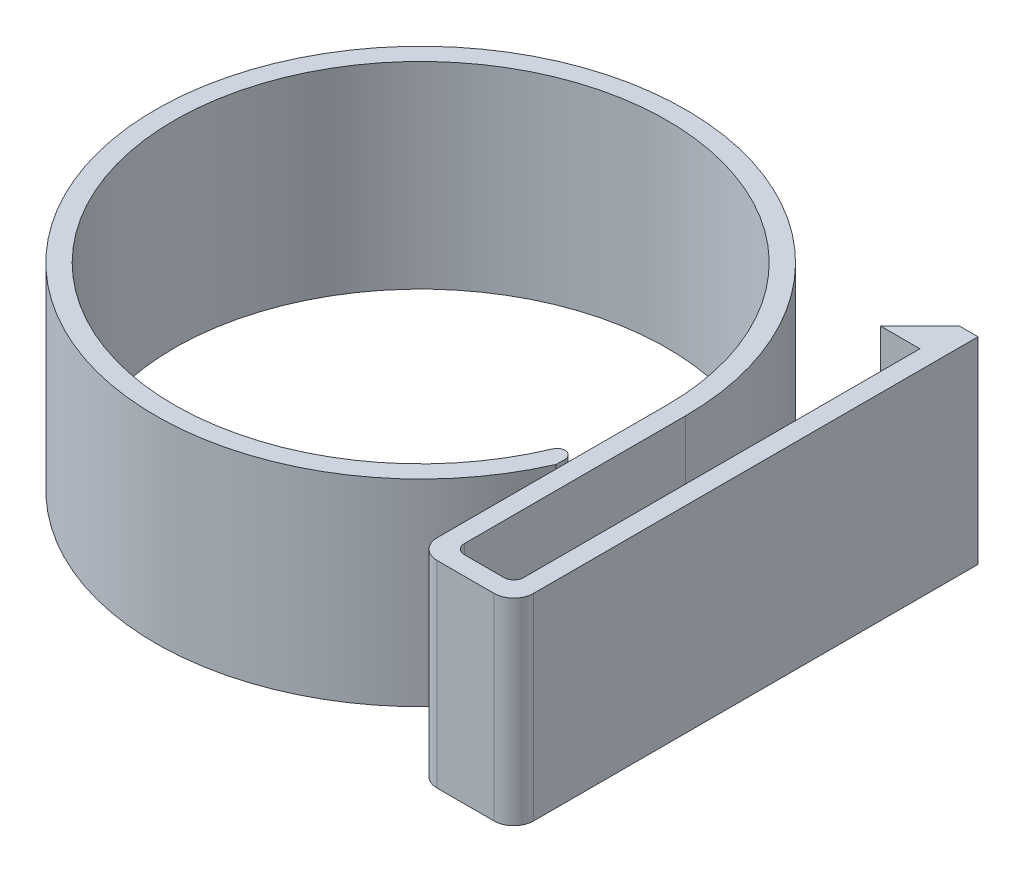
from build123d import *

# Parameters (mm, degrees)
BOSS_EXTRUDE1_DEPTH = 12.7
FILLET2_R           = 0.635
FILLET3_R           = 1.27
FILLET4_R           = 0.508


with BuildPart() as part:
    # Sketch1 → Boss-Extrude1 (new body)
    with BuildSketch(Plane(origin=(0, 0, 0), x_dir=(1, 0, 0), z_dir=(0, 1, 0))):
        with BuildLine():
            Line((17.075, 0), (17.075, -14.88542834))
            Line((17.075, -14.88542834), (20.885, -14.88542834))
            Line((20.885, -14.88542834), (20.885, 10.51457166))
            Line((20.885, 10.51457166), (20.885, 11.27657166))
            Line((20.885, 11.27657166), (18.345, 11.27657166))
            Line((18.345, 11.27657166), (20.885, 13.81657166))
            Line((20.885, 13.81657166), (22.085, 13.81657166))
            Line((22.085, 13.81657166), (22.085, 10.51457166))
            Line((22.085, 10.51457166), (22.085, -16.08542834))
            Line((22.085, -16.08542834), (15.875, -16.08542834))
            Line((15.875, -16.08542834), (15.875, 0))
            ThreePointArc((15.875, 0), (-15.811372489, 1.419903166), (15.621, -2.828424296))
            Line((15.621, -2.828424296), (15.621, -6.89492451))
            ThreePointArc((15.621, -6.89492451), (-16.707546199, 3.52328327), (17.075, 0))
        make_face()
    extrude(amount=BOSS_EXTRUDE1_DEPTH)

    # Fillet2
    fillet2_edges = [part.edges().sort_by_distance(p)[0] for p in [
        (17.075, 6.35, 14.88542834),
        (20.885, 6.35, 14.88542834),
    ]]
    fillet(fillet2_edges, radius=FILLET2_R)

    # Fillet3
    fillet3_edges = [part.edges().sort_by_distance(p)[0] for p in [
        (22.085, 6.35, 16.08542834),
        (15.875, 6.35, 16.08542834),
    ]]
    fillet(fillet3_edges, radius=FILLET3_R)

    # Fillet4
    fillet4_edges = [part.edges().sort_by_distance(p)[0] for p in [
        (15.621, 6.35, 2.828424296),
    ]]
    fillet(fillet4_edges, radius=FILLET4_R)


solid = part.part
